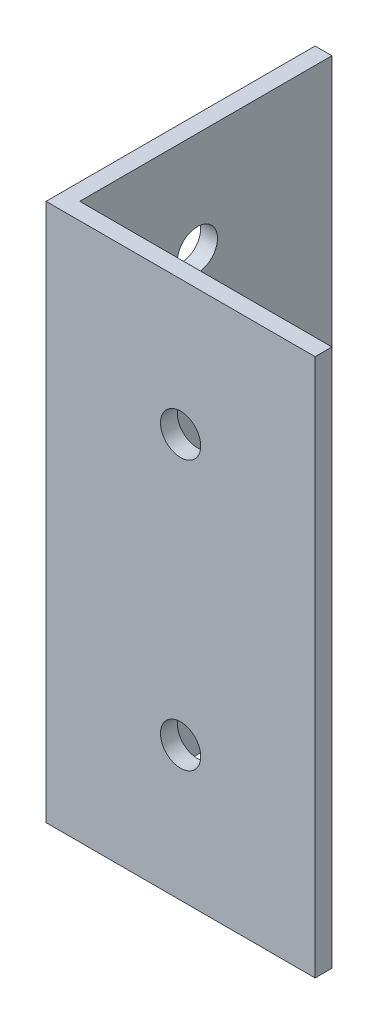
from build123d import *

# Parameters (mm, degrees)
BOSS_EXTRUDE1_DEPTH   = 50.8
F_6_CLEARANCE_HOLE1_D = 3.7973
F_6_CLEARANCE_HOLE2_D = 3.7973


with BuildPart() as part:
    # Sketch1 → Boss-Extrude1 (new body)
    with BuildSketch(Plane(origin=(0, 0, 0), x_dir=(1, 0, 0), z_dir=(0, 1, 0))):
        Polygon((0, 25.4), (1.5875, 25.4), (1.5875, 1.5875), (25.4, 1.5875), (25.4, 0), (0, 0), align=None)
    extrude(amount=BOSS_EXTRUDE1_DEPTH)

    # #6 Clearance Hole1 (through all)
    with Locations(Plane(origin=(0, 0, -1.5875), x_dir=(-1, 0, 0), z_dir=(0, 0, -1))):
        with Locations((-12.7, 38.1), (-12.7, 12.7)):
            Hole(F_6_CLEARANCE_HOLE1_D / 2)

    # #6 Clearance Hole2 (through all)
    with Locations(Plane(origin=(1.5875, 0, 0), x_dir=(0, 0, -1), z_dir=(1, 0, 0))):
        with Locations((12.7, 41.275), (12.7, 9.525)):
            Hole(F_6_CLEARANCE_HOLE2_D / 2)


solid = part.part
